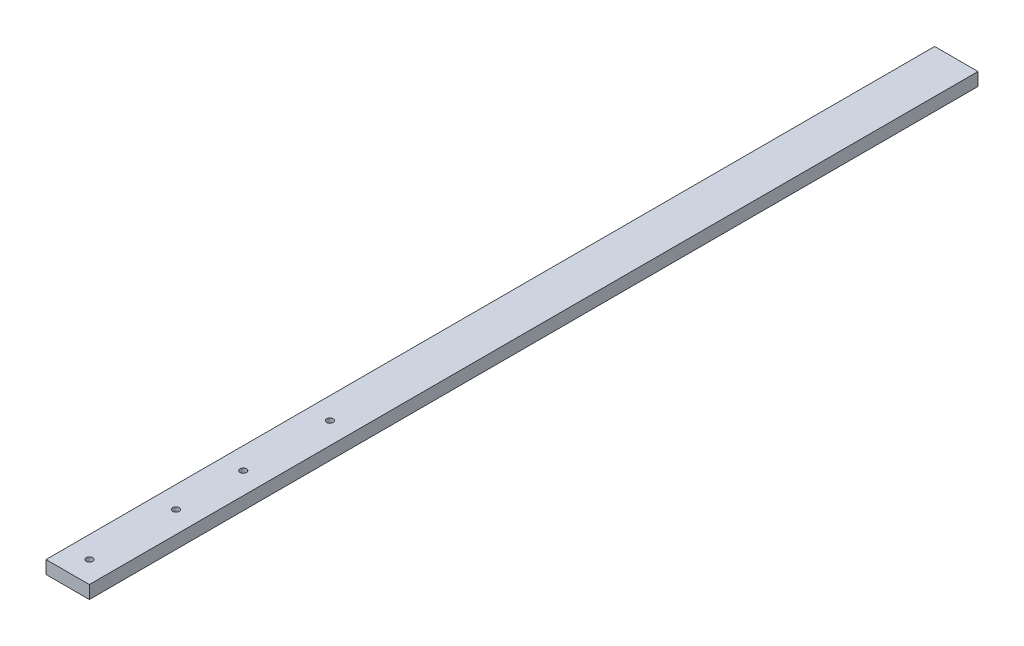
from build123d import *

# Parameters (mm, degrees)
SKETCH1_W           = 20
SKETCH1_H           = 410
BOSS_EXTRUDE1_DEPTH = 6
SKETCH2_R           = 1.5
CUT_EXTRUDE1_DEPTH  = 7


with BuildPart() as part:
    # Sketch1 → Boss-Extrude1 (new body)
    with BuildSketch(Plane(origin=(0, 0, 0), x_dir=(1, 0, 0), z_dir=(0, 1, 0))):
        Rectangle(SKETCH1_W, SKETCH1_H)
    extrude(amount=BOSS_EXTRUDE1_DEPTH)

    # Sketch2 → Cut-Extrude1 (cut, through all)
    with BuildSketch(Plane(origin=(0, 6, 0), x_dir=(1, 0, 0), z_dir=(0, 1, 0))):
        with Locations((0, -195)):
            Circle(SKETCH2_R)
        with Locations((0, -155)):
            Circle(SKETCH2_R)
        with Locations((0, -124)):
            Circle(SKETCH2_R)
        with Locations((0, -84)):
            Circle(SKETCH2_R)
    extrude(amount=-CUT_EXTRUDE1_DEPTH, mode=Mode.SUBTRACT)


solid = part.part
